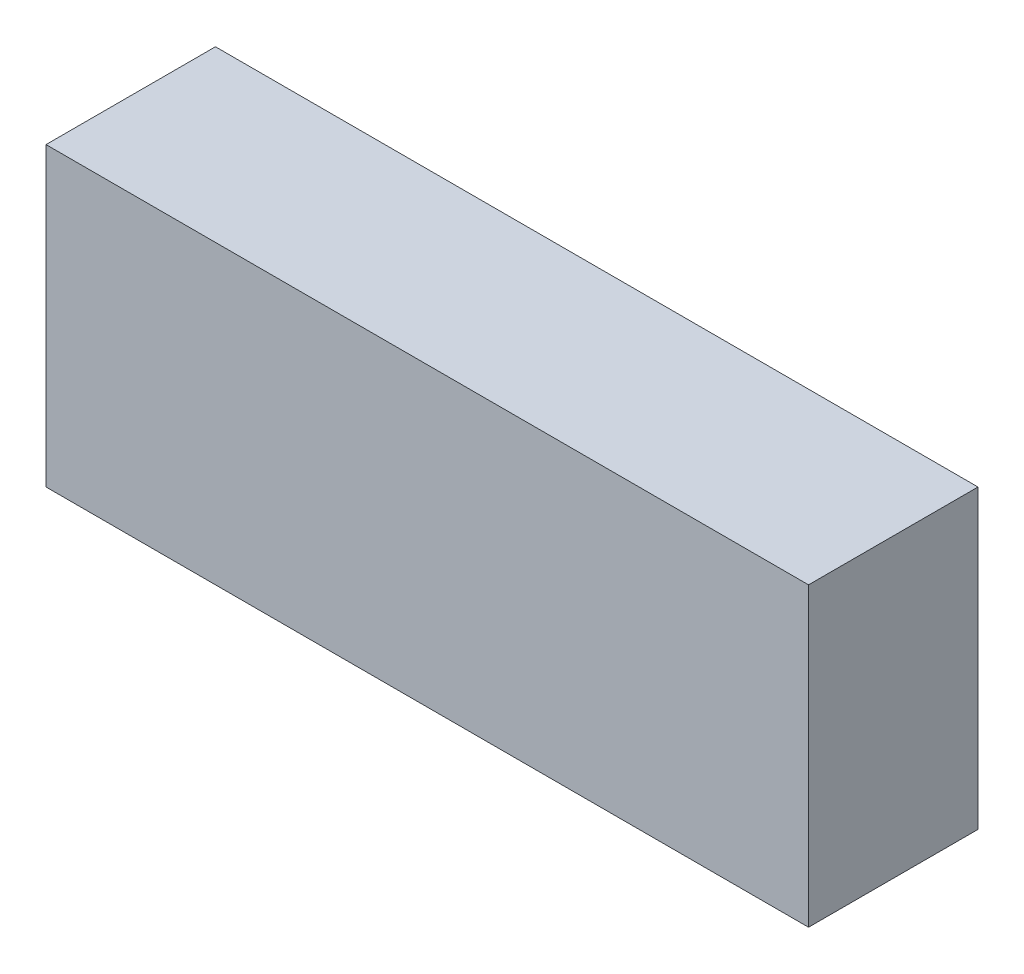
from build123d import *

# Parameters (mm, degrees)
ESQUISSE1_W        = 90
ESQUISSE1_H        = 35
BOSS_EXTRU_1_DEPTH = 20


with BuildPart() as part:
    # Esquisse1 → Boss.-Extru.1 (new body)
    with BuildSketch(Plane.XY):
        with Locations((-45, 17.5)):
            Rectangle(ESQUISSE1_W, ESQUISSE1_H)
    extrude(amount=BOSS_EXTRU_1_DEPTH)


solid = part.part
